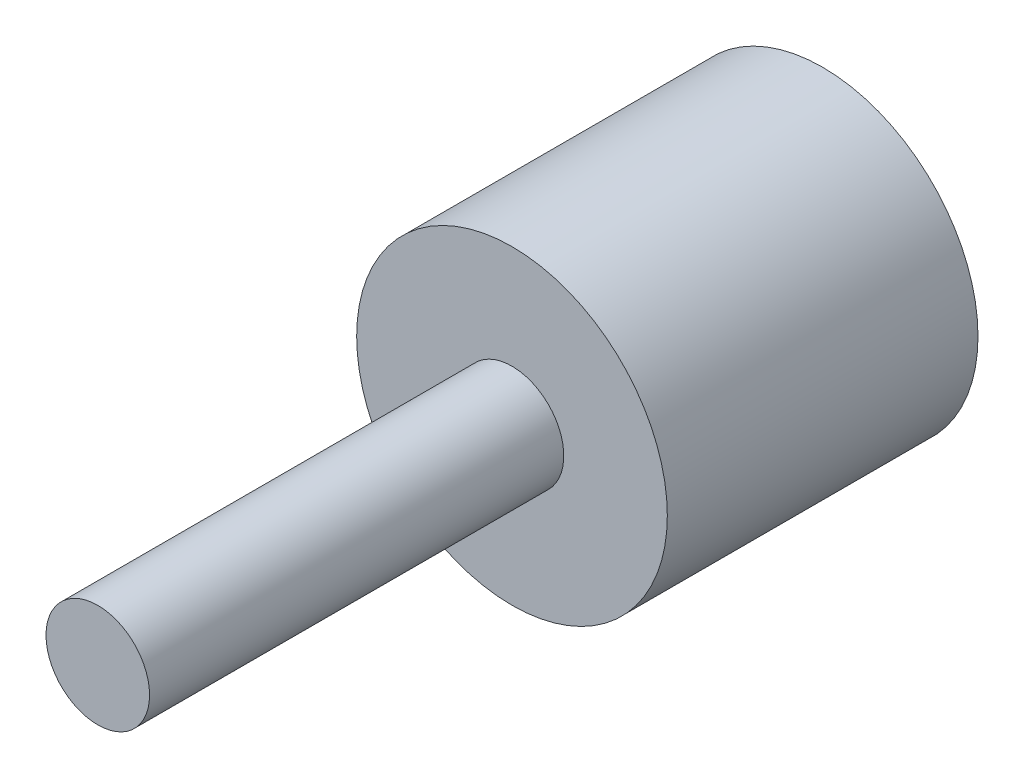
from build123d import *

# Parameters (mm, degrees)
SKETCH1_R           = 7.5
BOSS_EXTRUDE1_DEPTH = 15
SKETCH2_R           = 2.5
BOSS_EXTRUDE2_DEPTH = 20
SKETCH3_R           = 2.5
CUT_EXTRUDE1_DEPTH  = 15


with BuildPart() as part:
    # Sketch1 → Boss-Extrude1 (new body)
    with BuildSketch(Plane.XY):
        Circle(SKETCH1_R)
    extrude(amount=BOSS_EXTRUDE1_DEPTH)

    # Sketch2 → Boss-Extrude2 (add)
    with BuildSketch(Plane.XY.offset(15)):
        Circle(SKETCH2_R)
    extrude(amount=BOSS_EXTRUDE2_DEPTH)

    # Sketch3 → Cut-Extrude1 (cut)
    with BuildSketch(Plane(origin=(0, 0, 0), x_dir=(-1, 0, 0), z_dir=(0, 0, -1))):
        Circle(SKETCH3_R)
    extrude(amount=-CUT_EXTRUDE1_DEPTH, mode=Mode.SUBTRACT)


solid = part.part
